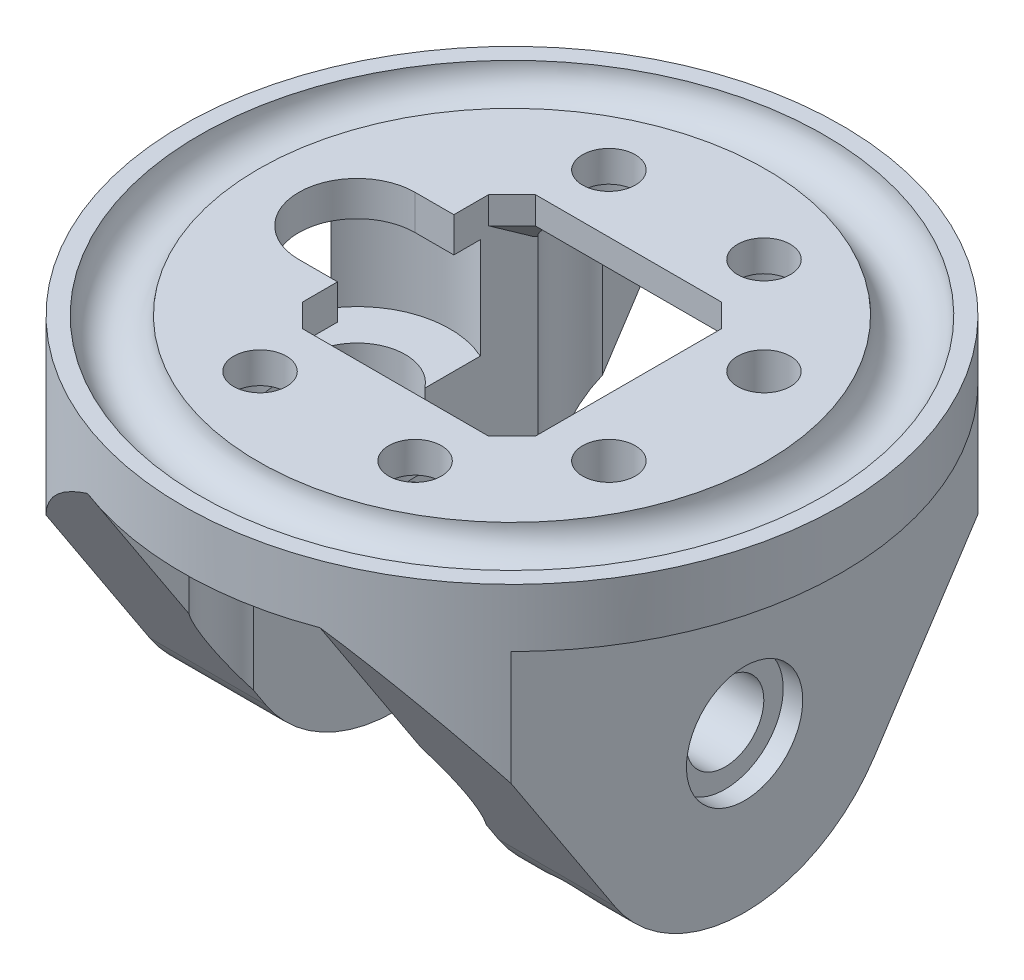
from build123d import *

# Parameters (mm, degrees)
CUT_EXTRUDE1_DEPTH      = 5.7625
SKETCH4_R               = 7.62
CUT_EXTRUDE2_DEPTH      = 1.905
BOSS_EXTRUDE1_DEPTH     = 50.8
SKETCH6_R               = 3.175
CUT_EXTRUDE3_DEPTH      = 27.9875
CUT_EXTRUDE3_DEPTH_BACK = 27.9875
SKETCH7_R               = 7.62
CUT_EXTRUDE4_DEPTH      = 6.35
SKETCH8_R               = 3.96875
CUT_EXTRUDE5_DEPTH      = 2.7686
SKETCH9_R               = 3.2385
CUT_EXTRUDE6_DEPTH      = 0.635
CHAMFER1_SIZE           = 1.905
CHAMFER2_SIZE           = 2.54
SKETCH10_R              = 2.159
CUT_EXTRUDE7_DEPTH      = 3.38125
CUT_EXTRUDE7_DEPTH_BACK = 31.44825
CUT_EXTRUDE8_START      = -2.54
SKETCH11_R              = 4.1275
CUT_EXTRUDE8_DEPTH      = 31.2895001
CUT_EXTRUDE9_START      = -22.225
SKETCH12_R              = 3.556
CUT_EXTRUDE9_DEPTH      = 11.6045001
SKETCH13_R              = 4.7625
CUT_EXTRUDE10_DEPTH     = 1.6002


with BuildPart() as part:
    # Sketch2 → Revolve1 (revolve)
    with BuildSketch(Plane.XY):
        with BuildLine():
            Line((0, 0), (0, 2.38125))
            Line((0, 2.38125), (-20.767844423, 2.38125))
            ThreePointArc((-20.767844423, 2.38125), (-23.1775, 0.09525), (-25.587155577, 2.38125))
            Line((-25.587155577, 2.38125), (-26.9875, 2.38125))
            Line((-26.9875, 2.38125), (-26.9875, -2.38125))
            Line((-26.9875, -2.38125), (0, -2.38125))
            Line((0, -2.38125), (0, 0))
        make_face()
    revolve(axis=Axis((0, 0, 0), (0, 1, 0)))

    # Sketch3 → Cut-Extrude1 (cut, through all)
    with BuildSketch(Plane(origin=(0, 2.38125, 0), x_dir=(1, 0, 0), z_dir=(0, 1, 0))):
        with BuildLine():
            Line((-9.525, -9.525), (9.525, -9.525))
            Line((9.525, -9.525), (9.525, 9.525))
            Line((9.525, 9.525), (-9.525, 9.525))
            Line((-9.525, 9.525), (-9.525, 4.7625))
            Line((-9.525, 4.7625), (-12.7, 4.7625))
            ThreePointArc((-12.7, 4.7625), (-17.4625, 0), (-12.7, -4.7625))
            Line((-12.7, -4.7625), (-9.525, -4.7625))
            Line((-9.525, -4.7625), (-9.525, -9.525))
        make_face()
    extrude(amount=-CUT_EXTRUDE1_DEPTH, mode=Mode.SUBTRACT)

    # Sketch4 → Cut-Extrude2 (cut)
    with BuildSketch(Plane.XZ.offset(2.38125)):
        with Locations((-12.7, 0)):
            Circle(SKETCH4_R)
    extrude(amount=-CUT_EXTRUDE2_DEPTH, mode=Mode.SUBTRACT)

    # Sketch5 → Boss-Extrude1 (add)
    with BuildSketch(Plane.XZ.offset(2.38125)):
        with BuildLine():
            Line((-9.525, -25.250733281), (-9.525, 25.250733281))
            ThreePointArc((-9.525, 25.250733281), (-14.613052318, 22.688848763), (-19.05, 19.116031394))
            Line((-19.05, 19.116031394), (-19.05, -19.116031394))
            ThreePointArc((-19.05, -19.116031394), (-14.613052318, -22.688848763), (-9.525, -25.250733281))
        make_face()
        with BuildLine():
            Line((9.525, -25.250733281), (9.525, 25.250733281))
            ThreePointArc((9.525, 25.250733281), (14.613052318, 22.688848763), (19.05, 19.116031394))
            Line((19.05, 19.116031394), (19.05, -19.116031394))
            ThreePointArc((19.05, -19.116031394), (14.613052318, -22.688848763), (9.525, -25.250733281))
        make_face()
    extrude(amount=BOSS_EXTRUDE1_DEPTH)

    # Sketch6 → Cut-Extrude3 (cut, two sides)
    with BuildSketch(Plane(origin=(0, 0, 0), x_dir=(0, 0, -1), z_dir=(1, 0, 0))) as cut_extrude3_sk:
        with Locations((0, -17.74825)):
            Circle(SKETCH6_R)
        with BuildLine():
            Line((-25.250733281, -2.38125), (-25.250733281, -53.18125))
            Line((-25.250733281, -53.18125), (25.250733281, -53.18125))
            Line((25.250733281, -53.18125), (25.250733281, -2.38125))
            Line((25.250733281, -2.38125), (10.623124822, -24.708078951))
            ThreePointArc((10.623124822, -24.708078951), (0, -30.44825), (-10.623124822, -24.708078951))
            Line((-10.623124822, -24.708078951), (-25.250733281, -2.38125))
        make_face()
    extrude(amount=CUT_EXTRUDE3_DEPTH, mode=Mode.SUBTRACT)
    extrude(cut_extrude3_sk.sketch, amount=-CUT_EXTRUDE3_DEPTH_BACK, mode=Mode.SUBTRACT)

    # Sketch7 → Cut-Extrude4 (cut)
    with BuildSketch(Plane(origin=(0, -2.38125, 0), x_dir=(1, 0, 0), z_dir=(0, 1, 0))):
        with Locations((-12.7, 0)):
            Circle(SKETCH7_R)
    extrude(amount=-CUT_EXTRUDE4_DEPTH, mode=Mode.SUBTRACT)

    # Sketch8 → Cut-Extrude5 (cut)
    with BuildSketch(Plane(origin=(0, -8.73125, 0), x_dir=(1, 0, 0), z_dir=(0, 1, 0))):
        with Locations((-12.7, 0)):
            Circle(SKETCH8_R)
    extrude(amount=-CUT_EXTRUDE5_DEPTH, mode=Mode.SUBTRACT)

    # Sketch9 → Cut-Extrude6 (cut)
    with BuildSketch(Plane(origin=(0, -11.49985, 0), x_dir=(1, 0, 0), z_dir=(0, 1, 0))):
        with Locations((-12.7, 0)):
            Circle(SKETCH9_R)
    extrude(amount=-CUT_EXTRUDE6_DEPTH, mode=Mode.SUBTRACT)

    # Chamfer1
    chamfer1_edges = [part.edges().sort_by_distance(p)[0] for p in [
        (9.525, 0, -9.525),
        (9.525, 0, 9.525),
        (-9.525, 0, 9.525),
        (-9.525, 0, -9.525),
    ]]
    chamfer(chamfer1_edges, length=CHAMFER1_SIZE)

    # Chamfer2
    chamfer2_edges = [part.edges().sort_by_distance(p)[0] for p in [
        (0, -2.38125, 9.525),
        (0, -2.38125, -9.525),
        (-8.5725, -2.38125, 8.5725),
        (8.5725, -2.38125, 8.5725),
        (8.5725, -2.38125, -8.5725),
        (-8.5725, -2.38125, -8.5725),
    ]]
    chamfer(chamfer2_edges, length=CHAMFER2_SIZE)

    # Sketch10 → Cut-Extrude7 (cut, two sides)
    with BuildSketch(Plane(origin=(0, 0, 0), x_dir=(1, 0, 0), z_dir=(0, 1, 0))) as cut_extrude7_sk:
        with Locations((-6.35, 14.2875)):
            Circle(SKETCH10_R)
        with Locations((-6.35, -14.2875)):
            Circle(SKETCH10_R)
        with Locations((6.35, -14.2875)):
            Circle(SKETCH10_R)
        with Locations((6.35, 14.2875)):
            Circle(SKETCH10_R)
        with Locations((14.2875, 6.35)):
            Circle(SKETCH10_R)
        with Locations((14.2875, -6.35)):
            Circle(SKETCH10_R)
    extrude(amount=CUT_EXTRUDE7_DEPTH, mode=Mode.SUBTRACT)
    extrude(cut_extrude7_sk.sketch, amount=-CUT_EXTRUDE7_DEPTH_BACK, mode=Mode.SUBTRACT)

    # Sketch11 → Cut-Extrude8 (cut, through all)
    with BuildSketch(Plane(origin=(0, 2.38125, 0), x_dir=(1, 0, 0), z_dir=(0, 1, 0)).offset(CUT_EXTRUDE8_START)):
        with Locations((-6.35, 14.2875)):
            Circle(SKETCH11_R)
        with Locations((6.35, 14.2875)):
            Circle(SKETCH11_R)
        with Locations((6.35, -14.2875)):
            Circle(SKETCH11_R)
        with Locations((-6.35, -14.2875)):
            Circle(SKETCH11_R)
    extrude(amount=-CUT_EXTRUDE8_DEPTH, mode=Mode.SUBTRACT)

    # Sketch12 → Cut-Extrude9 (cut, through all)
    with BuildSketch(Plane(origin=(0, 2.38125, 0), x_dir=(1, 0, 0), z_dir=(0, 1, 0)).offset(CUT_EXTRUDE9_START)):
        with Locations((14.2875, 6.35)):
            Circle(SKETCH12_R)
        with Locations((14.2875, -6.35)):
            Circle(SKETCH12_R)
    extrude(amount=-CUT_EXTRUDE9_DEPTH, mode=Mode.SUBTRACT)

    # Sketch13 → Cut-Extrude10 (cut)
    with BuildSketch(Plane(origin=(19.05, 0, 0), x_dir=(0, 0, -1), z_dir=(1, 0, 0))):
        with Locations((0, -17.74825)):
            Circle(SKETCH13_R)
    extrude(amount=-CUT_EXTRUDE10_DEPTH, mode=Mode.SUBTRACT)


solid = part.part
